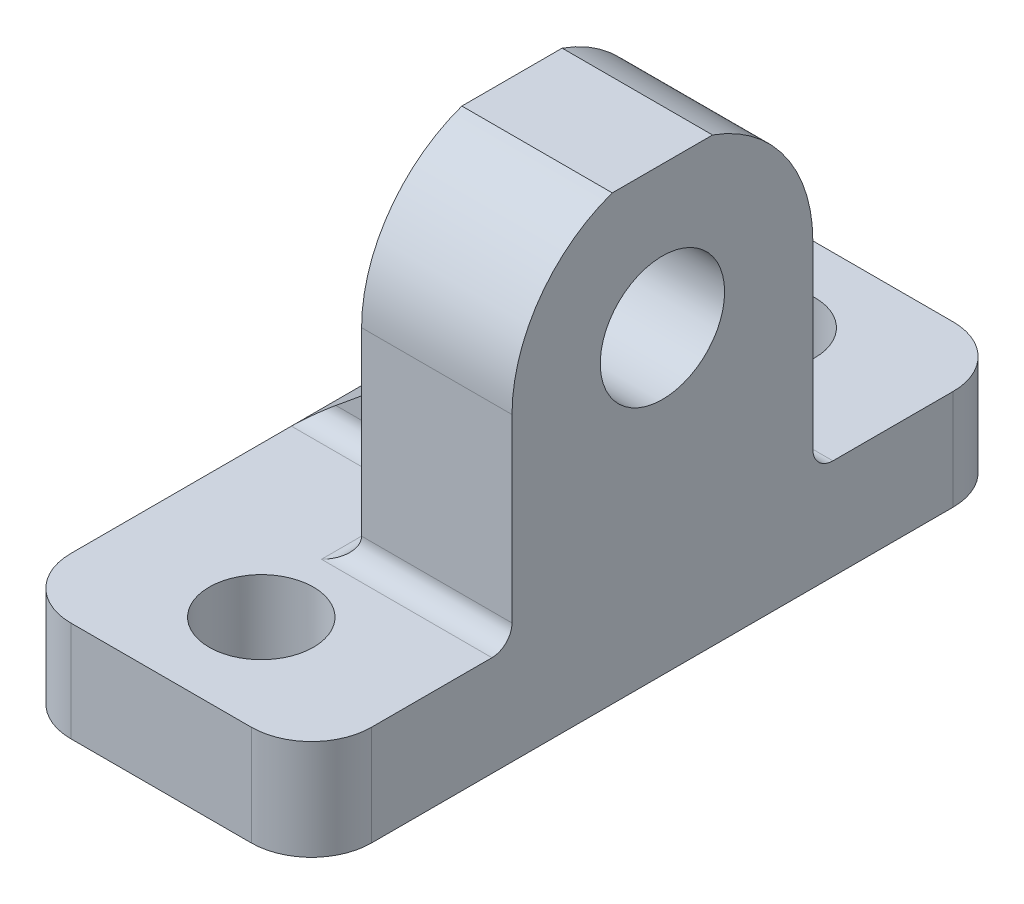
from build123d import *

# Parameters (mm, degrees)
SKETCH1_R           = 3.1
BOSS_EXTRUDE1_DEPTH = 15
SKETCH2_R           = 2.6
CUT_EXTRUDE2_DEPTH  = 32.912098558
CUT_EXTRUDE4_REACH  = 33.912
SKETCH3_W           = 7.5
SKETCH3_H           = 5
SKETCH4_W           = 7.5
SKETCH4_H           = 5.238037534
CUT_EXTRUDE5_DEPTH  = 5
FILLET1_R           = 1
FILLET2_R           = 3


with BuildPart() as part:
    # Sketch1 → Boss-Extrude1 (new body)
    with BuildSketch(Plane(origin=(0, 0, 0), x_dir=(0, 0, -1), z_dir=(1, 0, 0))):
        with BuildLine():
            Line((7.5, 2.5), (17.5, 2.5))
            Line((17.5, 2.5), (17.5, -2.5))
            Line((17.5, -2.5), (-17.5, -2.5))
            Line((-17.5, -2.5), (-17.5, 2.5))
            Line((-17.5, 2.5), (-7.5, 2.5))
            Line((-7.5, 2.5), (-7.5, 12.5))
            ThreePointArc((-7.5, 12.5), (-6.123724357, 16.830127019), (-2.5, 19.571067812))
            Line((-2.5, 19.571067812), (2.5, 19.571067812))
            ThreePointArc((2.5, 19.571067812), (6.123724357, 16.830127019), (7.5, 12.5))
            Line((7.5, 12.5), (7.5, 2.5))
        make_face()
        with Locations((0, 12.5)):
            Circle(SKETCH1_R, mode=Mode.SUBTRACT)
    extrude(amount=BOSS_EXTRUDE1_DEPTH)

    # Sketch2 → Cut-Extrude2 (cut, through all)
    with BuildSketch(Plane(origin=(0, 19.571067812, 0), x_dir=(1, 0, 0), z_dir=(0, 1, 0))):
        with Locations(Location((7.5, 12.5, 0), (0, 0, 270))):
            Circle(SKETCH2_R)
        with Locations(Location((7.5, -12.5, 0), (0, 0, 270))):
            Circle(SKETCH2_R)
    extrude(amount=-CUT_EXTRUDE2_DEPTH, mode=Mode.SUBTRACT)

    # Cut-Extrude4: up to this face of the body (flat: up to its plane)
    cut_extrude4_end = Plane(part.part.faces().sort_by_distance((7.5, 2.5, 17.319722436))[0])
    # Sketch3 → Cut-Extrude4 (cut, up to the picked face)
    with BuildSketch(Plane(origin=(0, 19.571067812, 0), x_dir=(1, 0, 0), z_dir=(0, 1, 0)), mode=Mode.PRIVATE) as cut_extrude4_sk1:
        with Locations((3.75, -5)):
            Rectangle(SKETCH3_W, SKETCH3_H)
    cut_extrude4_tool1 = split(extrude(cut_extrude4_sk1.sketch, amount=-CUT_EXTRUDE4_REACH, mode=Mode.PRIVATE), bisect_by=cut_extrude4_end, keep=Keep.BOTH, mode=Mode.PRIVATE)
    # Sketch3 → Cut-Extrude4 (cut, up to the picked face)
    with BuildSketch(Plane(origin=(0, 19.571067812, 0), x_dir=(1, 0, 0), z_dir=(0, 1, 0)), mode=Mode.PRIVATE) as cut_extrude4_sk2:
        with Locations((3.75, 5)):
            Rectangle(SKETCH3_W, SKETCH3_H)
    cut_extrude4_tool2 = split(extrude(cut_extrude4_sk2.sketch, amount=-CUT_EXTRUDE4_REACH, mode=Mode.PRIVATE), bisect_by=cut_extrude4_end, keep=Keep.BOTH, mode=Mode.PRIVATE)
    add(cut_extrude4_tool1.solids().sort_by(Axis((3.75, 19.571068, 5), (0, -1, 0)))[0], mode=Mode.SUBTRACT)
    add(cut_extrude4_tool2.solids().sort_by(Axis((3.75, 19.571068, -5), (0, -1, 0)))[0], mode=Mode.SUBTRACT)

    # Sketch4 → Cut-Extrude5 (cut)
    with BuildSketch(Plane.XY.offset(2.5)):
        Polygon((7.5, 8.666969722), (0, 2.5), (0, 10.666969722), (7.5, 10.666969722), align=None)
        with Locations((3.75, 16.952049045)):
            Rectangle(SKETCH4_W, SKETCH4_H)
    extrude(amount=-CUT_EXTRUDE5_DEPTH, mode=Mode.SUBTRACT)

    # Fillet1
    fillet1_edges = [part.edges().sort_by_distance(p)[0] for p in [
        (11.25, 2.5, 7.5),
        (11.25, 2.5, -7.5),
        (7.5, 2.5, -5),
        (3.75, 2.5, -2.5),
        (7.5, 2.5, 5),
        (3.75, 2.5, 2.5),
    ]]
    fillet(fillet1_edges, radius=FILLET1_R)

    # Fillet2
    fillet2_edges = [part.edges().sort_by_distance(p)[0] for p in [
        (0, 0, 17.5),
        (0, 0, -17.5),
        (15, 0, 17.5),
        (15, 0, -17.5),
    ]]
    fillet(fillet2_edges, radius=FILLET2_R)


solid = part.part
